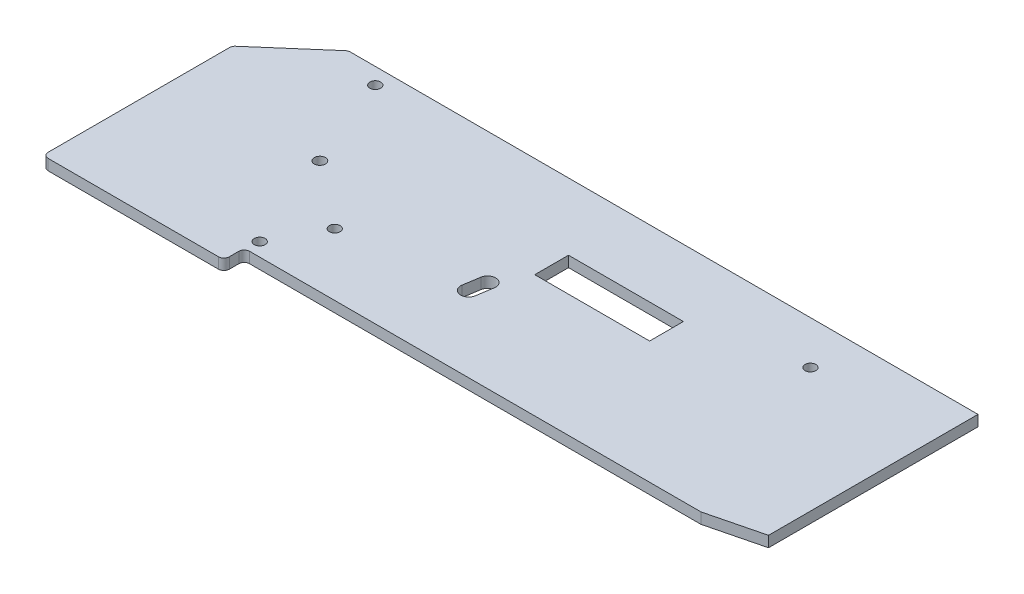
from build123d import *

# Parameters (mm, degrees)
SKETCH1_R               = 2
SKETCH1_R_2             = 2.075
PRIMARY_DEPTH           = 4
SWINGYBIT_PIN_START     = -4
SKETCH7_R               = 7.5
SKETCH7_R_2             = 2
SWINGYBIT_PIN_EXT_DEPTH = 6
WHEEL_PIN_START         = -4
SKETCH8_R               = 5
SKETCH8_R_2             = 2
SKETCH8_R_3             = 8.75
WHEEL_PIN_EXT_DEPTH     = 1.75
SKETCH10_W              = 42.5
SKETCH10_H              = 12.5
WINDOW_CUT_DEPTH        = 11
FILLET1_R               = 2
CHAMFER1_SIZE           = 0.5
CHAMFER1_SIZE2          = 0.866025404
CHAMFER1_PART_2_SIZE    = 0.5
CHAMFER1_PART_2_SIZE2   = 0.866025404
CHAMFER1_PART_3_SIZE    = 0.5
CHAMFER1_PART_3_SIZE2   = 0.866025404
CHAMFER1_PART_4_SIZE    = 0.5
CHAMFER1_PART_4_SIZE2   = 0.866025404
CHAMFER1_PART_5_SIZE    = 0.5
CHAMFER1_PART_5_SIZE2   = 0.866025404


with BuildPart() as part:
    # Sketch1 → Primary (new body)
    with BuildSketch(Plane(origin=(0, 0, 0), x_dir=(1, 0, 0), z_dir=(0, 1, 0))):
        Polygon((0, 0), (-23, -20), (-23, -90), (44, -90), (44, -82.5), (213, -82.5), (233, -77.5), (233, 0), align=None)
        with Locations((16, -6)):
            Circle(SKETCH1_R, mode=Mode.SUBTRACT)
        with Locations((30, -40.5)):
            Circle(SKETCH1_R_2, mode=Mode.SUBTRACT)
        with Locations((54.5, -59.5)):
            Circle(SKETCH1_R, mode=Mode.SUBTRACT)
        with Locations((44.75, -77.5)):
            Circle(SKETCH1_R, mode=Mode.SUBTRACT)
        with Locations((187, -16)):
            Circle(SKETCH1_R, mode=Mode.SUBTRACT)
    extrude(amount=PRIMARY_DEPTH)

    # Sketch7 → Swingybit_Pin Ext (add)
    with BuildSketch(Plane(origin=(0, 4, 0), x_dir=(1, 0, 0), z_dir=(0, 1, 0)).offset(SWINGYBIT_PIN_START)):
        with Locations((187, -16)):
            Circle(SKETCH7_R)
        with Locations((187, -16)):
            Circle(SKETCH7_R_2, mode=Mode.SUBTRACT)
    extrude(amount=-SWINGYBIT_PIN_EXT_DEPTH)

    # Sketch8 → Wheel_Pin Ext (add)
    with BuildSketch(Plane(origin=(0, 4, 0), x_dir=(1, 0, 0), z_dir=(0, 1, 0)).offset(WHEEL_PIN_START)):
        with Locations((16, -6)):
            Circle(SKETCH8_R)
        with Locations((16, -6)):
            Circle(SKETCH8_R_2, mode=Mode.SUBTRACT)
        with Locations((54.5, -59.5)):
            Circle(SKETCH8_R_3)
        with Locations((54.5, -59.5)):
            Circle(SKETCH8_R_2, mode=Mode.SUBTRACT)
    extrude(amount=-WHEEL_PIN_EXT_DEPTH)

    # Sketch10 → Window Cut (cut, through all)
    with BuildSketch(Plane(origin=(0, 4, 0), x_dir=(1, 0, 0), z_dir=(0, 1, 0))):
        with Locations((127.5, -31)):
            Rectangle(SKETCH10_W, SKETCH10_H)
        with BuildLine():
            Line((97.081439654, -48.031479895), (96.132758806, -54.031479895))
            ThreePointArc((96.132758806, -54.031479895), (98.396768435, -57.417387228), (101.949607057, -55.425542407))
            Line((101.949607057, -55.425542407), (103.044628631, -48.5))
            ThreePointArc((103.044628631, -48.5), (100.279610619, -45.509216914), (97.081439654, -48.031479895))
        make_face()
    extrude(amount=-WINDOW_CUT_DEPTH, mode=Mode.SUBTRACT)

    # Fillet1
    fillet1_edges = [part.edges().sort_by_distance(p)[0] for p in [
        (44, 2, 82.5),
        (0, 2, 0),
        (-23, 2, 20),
        (-23, 2, 90),
        (44, 2, 90),
    ]]
    fillet(fillet1_edges, radius=FILLET1_R)

    # Chamfer1
    chamfer1_edges = [part.edges().sort_by_distance(p)[0] for p in [
        (27.925, 0, 40.5),
    ]]
    chamfer1_side = [part.faces().sort_by_distance(p)[0] for p in [
        (27.925, 2, 40.5),
    ]]
    chamfer(chamfer1_edges, length=CHAMFER1_SIZE, length2=CHAMFER1_SIZE2, reference=chamfer1_side[0])

    # Chamfer1 part 2
    chamfer1_part_2_edges = [part.edges().sort_by_distance(p)[0] for p in [
        (42.75, 0, 77.5),
    ]]
    chamfer1_part_2_side = [part.faces().sort_by_distance(p)[0] for p in [
        (42.75, 2, 77.5),
    ]]
    chamfer(chamfer1_part_2_edges, length=CHAMFER1_PART_2_SIZE, length2=CHAMFER1_PART_2_SIZE2, reference=chamfer1_part_2_side[0])

    # Chamfer1 part 3
    chamfer1_part_3_edges = [part.edges().sort_by_distance(p)[0] for p in [
        (185, -6, 16),
    ]]
    chamfer1_part_3_side = [part.faces().sort_by_distance(p)[0] for p in [
        (179.712132034, -6, 16),
    ]]
    chamfer(chamfer1_part_3_edges, length=CHAMFER1_PART_3_SIZE, length2=CHAMFER1_PART_3_SIZE2, reference=chamfer1_part_3_side[0])

    # Chamfer1 part 4
    chamfer1_part_4_edges = [part.edges().sort_by_distance(p)[0] for p in [
        (14, -1.75, 6),
    ]]
    chamfer1_part_4_side = [part.faces().sort_by_distance(p)[0] for p in [
        (11.141421356, -1.75, 6),
    ]]
    chamfer(chamfer1_part_4_edges, length=CHAMFER1_PART_4_SIZE, length2=CHAMFER1_PART_4_SIZE2, reference=chamfer1_part_4_side[0])

    # Chamfer1 part 5
    chamfer1_part_5_edges = [part.edges().sort_by_distance(p)[0] for p in [
        (52.5, -1.75, 59.5),
    ]]
    chamfer1_part_5_side = [part.faces().sort_by_distance(p)[0] for p in [
        (45.997487373, -1.75, 59.5),
    ]]
    chamfer(chamfer1_part_5_edges, length=CHAMFER1_PART_5_SIZE, length2=CHAMFER1_PART_5_SIZE2, reference=chamfer1_part_5_side[0])


solid = part.part
